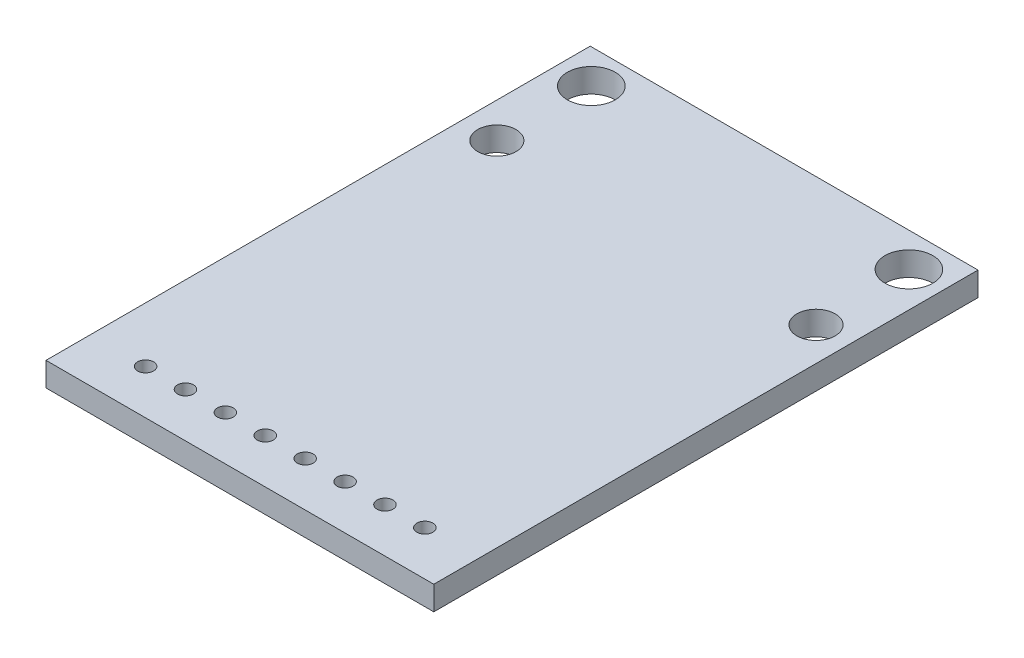
from build123d import *

# Parameters (mm, degrees)
SKETCH1_W             = 24.3
SKETCH1_H             = 34.1
BOSS_EXTRUDE1_DEPTH   = 1.5
F_3_0MM_DOWEL_HOLE1_D = 3
M2_CLEARANCE_HOLE1_D  = 2.4
CUT_EXTRUDE1_REACH    = 3.5
SKETCH9_R             = 0.5


with BuildPart() as part:
    # Sketch1 → Boss-Extrude1 (new body)
    with BuildSketch(Plane(origin=(0, 0, 0), x_dir=(1, 0, 0), z_dir=(0, 1, 0))):
        Rectangle(SKETCH1_W, SKETCH1_H)
    extrude(amount=BOSS_EXTRUDE1_DEPTH)

    # Ø3.0mm Dowel Hole1 (through all)
    with Locations(Plane(origin=(0, 1.5, 0), x_dir=(1, 0, 0), z_dir=(0, 1, 0))):
        with Locations((-9.95, 14.92), (9.95, 14.92)):
            Hole(F_3_0MM_DOWEL_HOLE1_D / 2)

    # M2 Clearance Hole1 (through all)
    with Locations(Plane(origin=(0, 1.5, 0), x_dir=(1, 0, 0), z_dir=(0, 1, 0))):
        with Locations((-9.95, 9), (10.05, 9)):
            Hole(M2_CLEARANCE_HOLE1_D / 2)

    # Sketch9 → Cut-Extrude1 (cut, up to next)
    with BuildSketch(Plane(origin=(0, 1.5, 0), x_dir=(1, 0, 0), z_dir=(0, 1, 0)), mode=Mode.PRIVATE) as cut_extrude1_sk1:
        with Locations((-8.7, -14.26)):
            Circle(SKETCH9_R)
    cut_extrude1_tool1 = extrude(cut_extrude1_sk1.sketch, amount=-CUT_EXTRUDE1_REACH, mode=Mode.PRIVATE) & part.part
    add(cut_extrude1_tool1.solids().sort_by_distance((-8.7, 1.5, 14.26))[0], mode=Mode.SUBTRACT)
    # Sketch9 → Cut-Extrude1 (cut, up to next)
    with BuildSketch(Plane(origin=(0, 1.5, 0), x_dir=(1, 0, 0), z_dir=(0, 1, 0)), mode=Mode.PRIVATE) as cut_extrude1_sk2:
        with Locations((-6.2, -14.26)):
            Circle(SKETCH9_R)
    cut_extrude1_tool2 = extrude(cut_extrude1_sk2.sketch, amount=-CUT_EXTRUDE1_REACH, mode=Mode.PRIVATE) & part.part
    add(cut_extrude1_tool2.solids().sort_by_distance((-6.2, 1.5, 14.26))[0], mode=Mode.SUBTRACT)
    # Sketch9 → Cut-Extrude1 (cut, up to next)
    with BuildSketch(Plane(origin=(0, 1.5, 0), x_dir=(1, 0, 0), z_dir=(0, 1, 0)), mode=Mode.PRIVATE) as cut_extrude1_sk3:
        with Locations((-3.7, -14.26)):
            Circle(SKETCH9_R)
    cut_extrude1_tool3 = extrude(cut_extrude1_sk3.sketch, amount=-CUT_EXTRUDE1_REACH, mode=Mode.PRIVATE) & part.part
    add(cut_extrude1_tool3.solids().sort_by_distance((-3.7, 1.5, 14.26))[0], mode=Mode.SUBTRACT)
    # Sketch9 → Cut-Extrude1 (cut, up to next)
    with BuildSketch(Plane(origin=(0, 1.5, 0), x_dir=(1, 0, 0), z_dir=(0, 1, 0)), mode=Mode.PRIVATE) as cut_extrude1_sk4:
        with Locations((-1.2, -14.26)):
            Circle(SKETCH9_R)
    cut_extrude1_tool4 = extrude(cut_extrude1_sk4.sketch, amount=-CUT_EXTRUDE1_REACH, mode=Mode.PRIVATE) & part.part
    add(cut_extrude1_tool4.solids().sort_by_distance((-1.2, 1.5, 14.26))[0], mode=Mode.SUBTRACT)
    # Sketch9 → Cut-Extrude1 (cut, up to next)
    with BuildSketch(Plane(origin=(0, 1.5, 0), x_dir=(1, 0, 0), z_dir=(0, 1, 0)), mode=Mode.PRIVATE) as cut_extrude1_sk5:
        with Locations((1.3, -14.26)):
            Circle(SKETCH9_R)
    cut_extrude1_tool5 = extrude(cut_extrude1_sk5.sketch, amount=-CUT_EXTRUDE1_REACH, mode=Mode.PRIVATE) & part.part
    add(cut_extrude1_tool5.solids().sort_by_distance((1.3, 1.5, 14.26))[0], mode=Mode.SUBTRACT)
    # Sketch9 → Cut-Extrude1 (cut, up to next)
    with BuildSketch(Plane(origin=(0, 1.5, 0), x_dir=(1, 0, 0), z_dir=(0, 1, 0)), mode=Mode.PRIVATE) as cut_extrude1_sk6:
        with Locations((3.8, -14.26)):
            Circle(SKETCH9_R)
    cut_extrude1_tool6 = extrude(cut_extrude1_sk6.sketch, amount=-CUT_EXTRUDE1_REACH, mode=Mode.PRIVATE) & part.part
    add(cut_extrude1_tool6.solids().sort_by_distance((3.8, 1.5, 14.26))[0], mode=Mode.SUBTRACT)
    # Sketch9 → Cut-Extrude1 (cut, up to next)
    with BuildSketch(Plane(origin=(0, 1.5, 0), x_dir=(1, 0, 0), z_dir=(0, 1, 0)), mode=Mode.PRIVATE) as cut_extrude1_sk7:
        with Locations((6.3, -14.26)):
            Circle(SKETCH9_R)
    cut_extrude1_tool7 = extrude(cut_extrude1_sk7.sketch, amount=-CUT_EXTRUDE1_REACH, mode=Mode.PRIVATE) & part.part
    add(cut_extrude1_tool7.solids().sort_by_distance((6.3, 1.5, 14.26))[0], mode=Mode.SUBTRACT)
    # Sketch9 → Cut-Extrude1 (cut, up to next)
    with BuildSketch(Plane(origin=(0, 1.5, 0), x_dir=(1, 0, 0), z_dir=(0, 1, 0)), mode=Mode.PRIVATE) as cut_extrude1_sk8:
        with Locations((8.8, -14.26)):
            Circle(SKETCH9_R)
    cut_extrude1_tool8 = extrude(cut_extrude1_sk8.sketch, amount=-CUT_EXTRUDE1_REACH, mode=Mode.PRIVATE) & part.part
    add(cut_extrude1_tool8.solids().sort_by_distance((8.8, 1.5, 14.26))[0], mode=Mode.SUBTRACT)


solid = part.part
